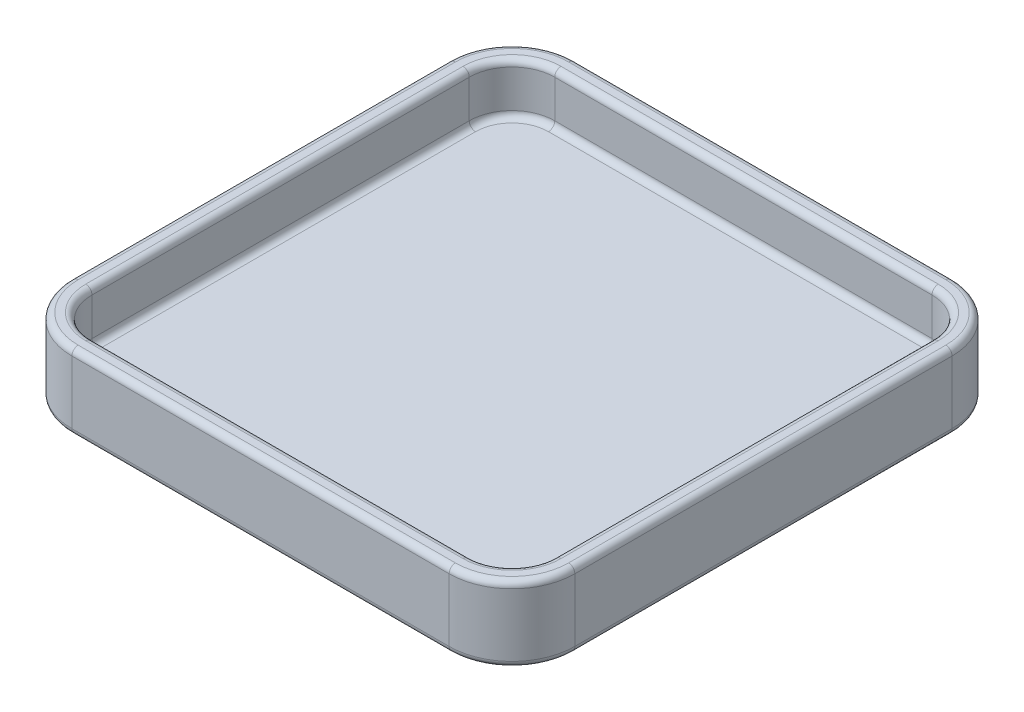
from build123d import *

# Parameters (mm, degrees)
BOSS_EXTRUDE1_DEPTH = 2
EXTRUDE_THIN1_START = 2
EXTRUDE_THIN1_DEPTH = 4
FILLET1_R           = 0.5


with BuildPart() as part:
    # Sketch1 → Boss-Extrude1 (new body)
    with BuildSketch(Plane(origin=(0, 0, 0), x_dir=(1, 0, 0), z_dir=(0, 1, 0))):
        with BuildLine():
            Line((-15, 20), (15, 20))
            ThreePointArc((15, 20), (18.535533906, 18.535533906), (20, 15))
            Line((20, 15), (20, -15))
            ThreePointArc((20, -15), (18.535533906, -18.535533906), (15, -20))
            Line((15, -20), (-15, -20))
            ThreePointArc((-15, -20), (-18.535533906, -18.535533906), (-20, -15))
            Line((-20, -15), (-20, 15))
            ThreePointArc((-20, 15), (-18.535533906, 18.535533906), (-15, 20))
        make_face()
    extrude(amount=BOSS_EXTRUDE1_DEPTH)

    # Sketch1_2 → Extrude-Thin1 (add)
    with BuildSketch(Plane(origin=(0, 0, 0), x_dir=(1, 0, 0), z_dir=(0, 1, 0)).offset(EXTRUDE_THIN1_START)):
        with BuildLine():
            Line((15, -20), (-15, -20))
            ThreePointArc((-15, -20), (-18.535533906, -18.535533906), (-20, -15))
            Line((-20, -15), (-20, 15))
            ThreePointArc((-20, 15), (-18.535533906, 18.535533906), (-15, 20))
            Line((-15, 20), (15, 20))
            ThreePointArc((15, 20), (18.535533906, 18.535533906), (20, 15))
            Line((20, 15), (20, -15))
            ThreePointArc((20, -15), (18.535533906, -18.535533906), (15, -20))
        make_face()
        with BuildLine():
            Line((15, -18.4), (-15, -18.4))
            ThreePointArc((-15, -18.4), (-17.404163056, -17.404163056), (-18.4, -15))
            Line((-18.4, -15), (-18.4, 15))
            ThreePointArc((-18.4, 15), (-17.404163056, 17.404163056), (-15, 18.4))
            Line((-15, 18.4), (15, 18.4))
            ThreePointArc((15, 18.4), (17.404163056, 17.404163056), (18.4, 15))
            Line((18.4, 15), (18.4, -15))
            ThreePointArc((18.4, -15), (17.404163056, -17.404163056), (15, -18.4))
        make_face(mode=Mode.SUBTRACT)
    extrude(amount=EXTRUDE_THIN1_DEPTH)

    # Fillet1
    fillet1_edges = [part.edges().sort_by_distance(p)[0] for p in [
        (0, 0, 20),
        (-18.535533906, 0, 18.535533906),
        (-18.535533906, 6, -18.535533906),
        (-18.535533906, 6, 18.535533906),
        (18.535533906, 6, 18.535533906),
        (18.535533906, 6, -18.535533906),
        (-18.4, 6, 0),
        (0, 6, -18.4),
        (18.4, 6, 0),
        (0, 6, 18.4),
        (-17.404163056, 2, -17.404163056),
        (-17.404163056, 2, 17.404163056),
        (17.404163056, 2, 17.404163056),
        (17.404163056, 2, -17.404163056),
        (-20, 6, 0),
        (0, 6, 20),
        (20, 6, 0),
        (0, 6, -20),
        (-17.404163056, 6, -17.404163056),
        (-18.4, 2, 0),
        (-17.404163056, 6, 17.404163056),
        (0, 2, 18.4),
        (17.404163056, 6, 17.404163056),
        (18.4, 2, 0),
        (17.404163056, 6, -17.404163056),
        (0, 2, -18.4),
        (-20, 0, 0),
        (-18.535533906, 0, -18.535533906),
        (0, 0, -20),
        (18.535533906, 0, -18.535533906),
        (20, 0, 0),
        (18.535533906, 0, 18.535533906),
    ]]
    fillet(fillet1_edges, radius=FILLET1_R)


solid = part.part
